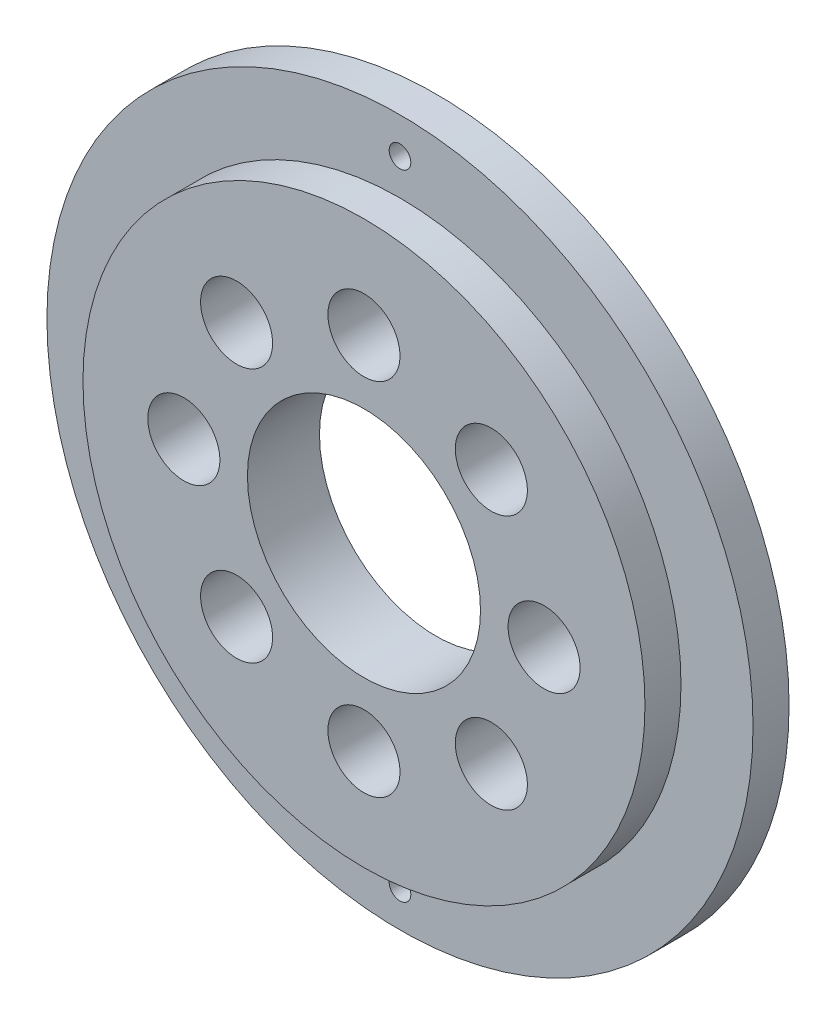
from build123d import *

# Parameters (mm, degrees)
ESQUISSE1_R             = 39
ESQUISSE1_R_2           = 16.175
BOSS_EXTRU_1_DEPTH      = 5
ESQUISSE2_R             = 49
BOSS_EXTRU_2_DEPTH      = 5
ESQUISSE3_R             = 16.175
ENL_V_MAT_EXTRU_1_DEPTH = 11
ESQUISSE4_R             = 1.5
ESQUISSE4_R_2           = 5
ENL_V_MAT_EXTRU_2_DEPTH = 11


with BuildPart() as part:
    # Esquisse1 → Boss.-Extru.1 (new body)
    with BuildSketch(Plane.XY):
        Circle(ESQUISSE1_R)
        Circle(ESQUISSE1_R_2, mode=Mode.SUBTRACT)
    extrude(amount=BOSS_EXTRU_1_DEPTH)

    # Esquisse2 → Boss.-Extru.2 (add)
    with BuildSketch(Plane(origin=(0, 0, 0), x_dir=(-1, 0, 0), z_dir=(0, 0, -1))):
        Circle(ESQUISSE2_R)
    extrude(amount=BOSS_EXTRU_2_DEPTH)

    # Esquisse3 → Enlèv. mat.-Extru.1 (cut, through all)
    with BuildSketch(Plane(origin=(0, 0, -5), x_dir=(-1, 0, 0), z_dir=(0, 0, -1))):
        Circle(ESQUISSE3_R)
    extrude(amount=-ENL_V_MAT_EXTRU_1_DEPTH, mode=Mode.SUBTRACT)

    # Esquisse4 → Enlèv. mat.-Extru.2 (cut, through all)
    with BuildSketch(Plane(origin=(0, 0, -5), x_dir=(-1, 0, 0), z_dir=(0, 0, -1))):
        with Locations((0, 44)):
            Circle(ESQUISSE4_R)
        with Locations((0, -44)):
            Circle(ESQUISSE4_R)
        with Locations((25, 0)):
            Circle(ESQUISSE4_R_2)
        with Locations((0, 25)):
            Circle(ESQUISSE4_R_2)
        with Locations((-25, 0)):
            Circle(ESQUISSE4_R_2)
        with Locations((0, -25)):
            Circle(ESQUISSE4_R_2)
        with Locations((-17.67766953, -17.67766953)):
            Circle(ESQUISSE4_R_2)
        with Locations((17.67766953, 17.67766953)):
            Circle(ESQUISSE4_R_2)
        with Locations((17.67766953, -17.67766953)):
            Circle(ESQUISSE4_R_2)
        with Locations((-17.67766953, 17.67766953)):
            Circle(ESQUISSE4_R_2)
    extrude(amount=-ENL_V_MAT_EXTRU_2_DEPTH, mode=Mode.SUBTRACT)


solid = part.part
